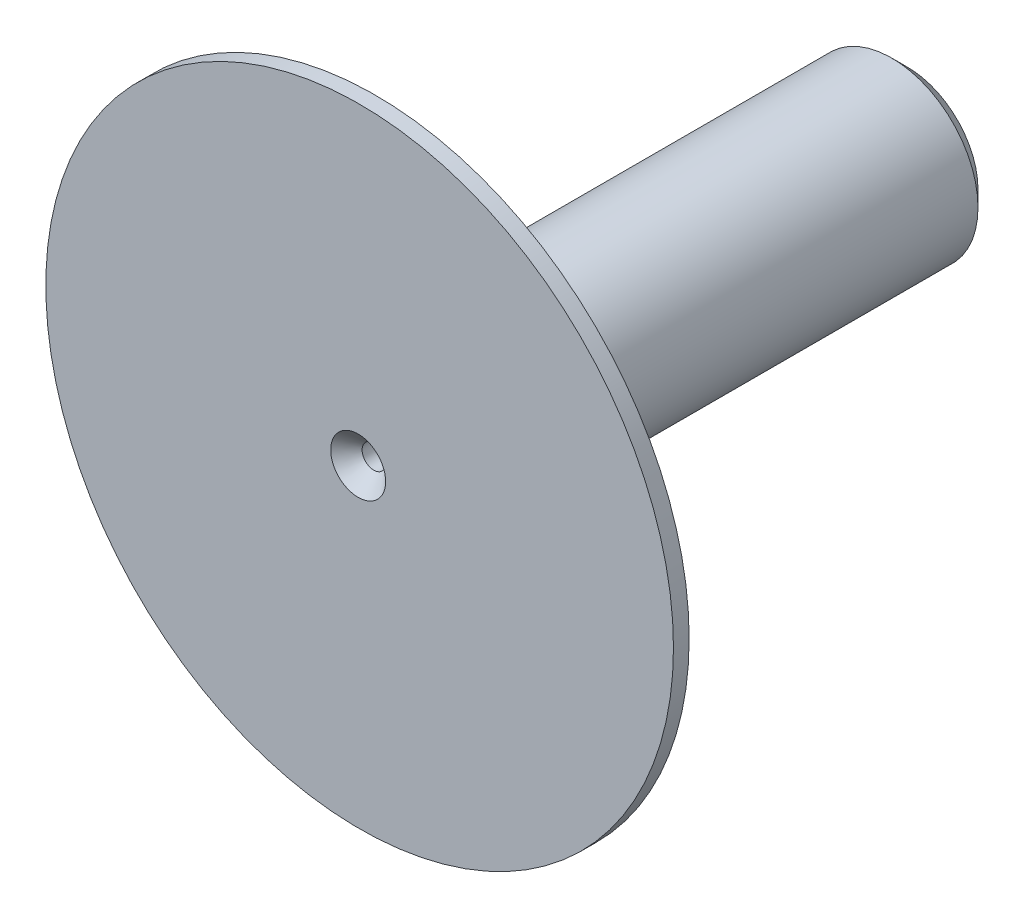
from build123d import *

# Parameters (mm, degrees)
SKETCH1_R           = 1.1
SKETCH1_R_2         = 0.15
BOSS_EXTRUDE1_DEPTH = 7
SKETCH2_R           = 4
SKETCH2_R_2         = 1.1
BOSS_EXTRUDE2_DEPTH = 0.2
CHAMFER1_SIZE       = 0.2


with BuildPart() as part:
    # Sketch1 → Boss-Extrude1 (new body)
    with BuildSketch(Plane.XY):
        Circle(SKETCH1_R)
        Circle(SKETCH1_R_2, mode=Mode.SUBTRACT)
    extrude(amount=BOSS_EXTRUDE1_DEPTH)

    # Sketch2 → Boss-Extrude2 (add)
    with BuildSketch(Plane.XY.offset(7)):
        with Locations((0.018669882, 0)):
            Circle(SKETCH2_R)
        Circle(SKETCH2_R_2, mode=Mode.SUBTRACT)
    extrude(amount=-BOSS_EXTRUDE2_DEPTH)

    # Chamfer1
    chamfer1_edges = [part.edges().sort_by_distance(p)[0] for p in [
        (-1.1, 0, 0),
        (-0.15, 0, 0),
        (-0.15, 0, 7),
    ]]
    chamfer(chamfer1_edges, length=CHAMFER1_SIZE)


solid = part.part
